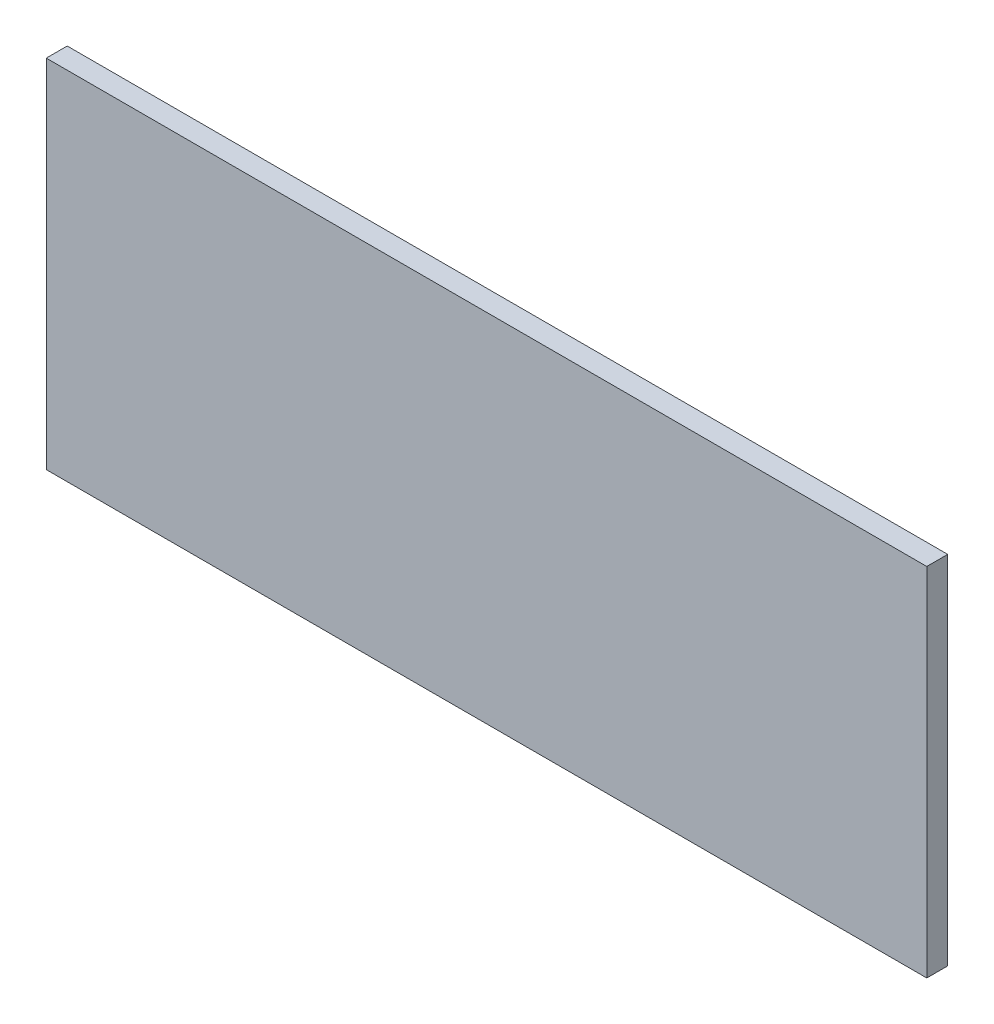
from build123d import *

# Parameters (mm, degrees)
SKETCH1_W           = 210
SKETCH1_H           = 85
BOSS_EXTRUDE1_DEPTH = 5


with BuildPart() as part:
    # Sketch1 → Boss-Extrude1 (new body)
    with BuildSketch(Plane.XY):
        with Locations((105, 42.5)):
            Rectangle(SKETCH1_W, SKETCH1_H)
    extrude(amount=BOSS_EXTRUDE1_DEPTH)


solid = part.part
